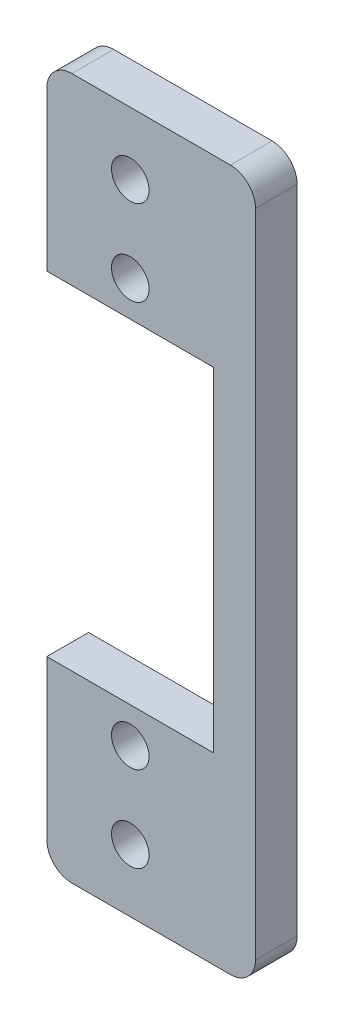
from build123d import *

# Parameters (mm, degrees)
BOSS_EXTRUDE1_DEPTH  = 5
M4_CLEARANCE_HOLE1_D = 4.5
FILLET1_R            = 3
M4_CLEARANCE_HOLE2_D = 4.5


with BuildPart() as part:
    # Sketch2 → Boss-Extrude1 (new body)
    with BuildSketch(Plane.XY):
        Polygon((15, 42), (-10, 42), (-10, 20), (10, 20), (10, -20), (-10, -20), (-10, -42), (15, -42), align=None)
    extrude(amount=BOSS_EXTRUDE1_DEPTH)

    # M4 Clearance Hole1 (through all)
    with Locations(Plane(origin=(0, 0, 0), x_dir=(1, 0, 0), z_dir=(0, 0, -1))):
        with Locations((0, -34.5), (0, 34.5)):
            Hole(M4_CLEARANCE_HOLE1_D / 2)

    # Fillet1
    fillet1_edges = [part.edges().sort_by_distance(p)[0] for p in [
        (-10, 42, 2.5),
        (15, 42, 2.5),
        (15, -42, 2.5),
        (-10, -42, 2.5),
    ]]
    fillet(fillet1_edges, radius=FILLET1_R)

    # M4 Clearance Hole2 (through all)
    with Locations(Plane(origin=(0, 0, 0), x_dir=(1, 0, 0), z_dir=(0, 0, -1))):
        with Locations((0, -24.25), (0, 24.25)):
            Hole(M4_CLEARANCE_HOLE2_D / 2)


solid = part.part
